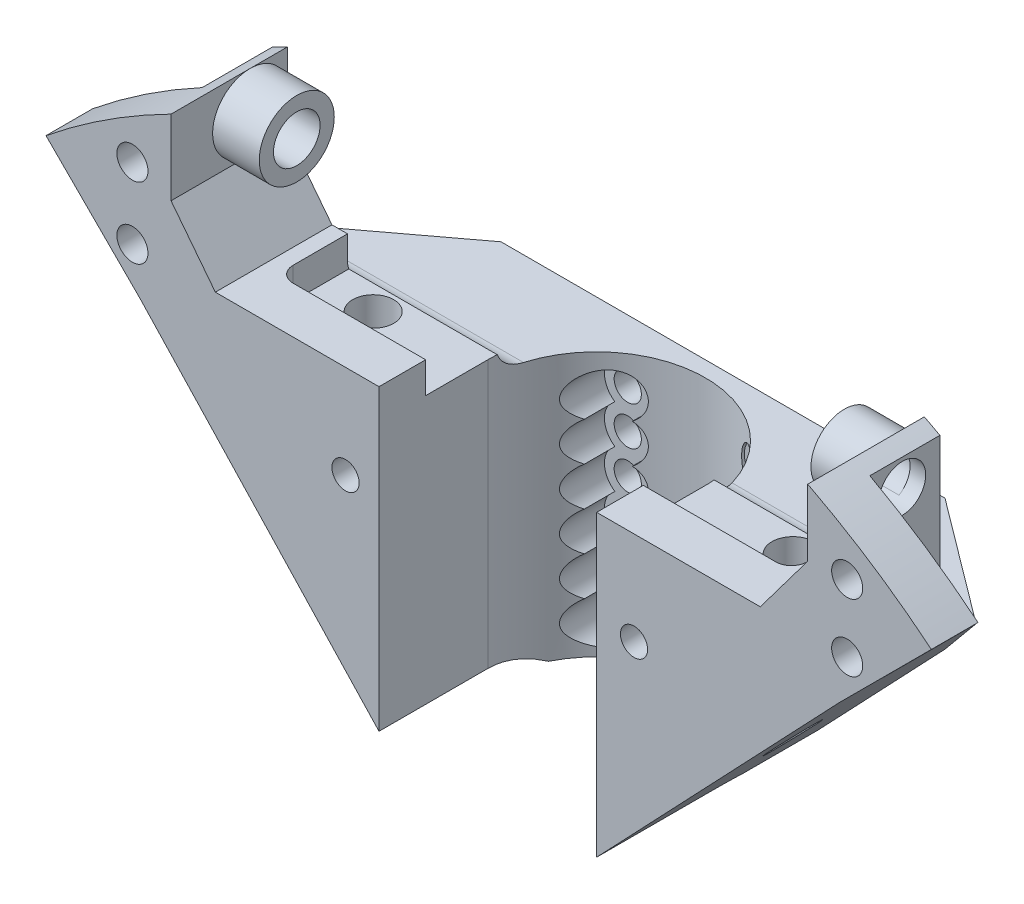
from build123d import *

# Parameters (mm, degrees)
BOSS_EXTRUDE1_DEPTH     = 30
CUT_EXTRUDE1_DEPTH      = 41
SKETCH4_R               = 1.999996
CUT_EXTRUDE2_DEPTH      = 31
CUT_EXTRUDE3_DEPTH      = 4
SKETCH6_W               = 121.245484342
SKETCH6_H               = 23
CUT_EXTRUDE4_DEPTH      = 15
SKETCH7_W               = 15.83545258
SKETCH7_H               = 23.773110715
SKETCH7_W_2             = 16.820183904
SKETCH7_H_2             = 28.417121519
CUT_EXTRUDE5_DEPTH      = 9
SKETCH8_R               = 4.826
SKETCH8_R_2             = 3
BOSS_EXTRUDE2_DEPTH     = 6
SKETCH10_R              = 4.29207203
SKETCH10_R_2            = 3
BOSS_EXTRUDE3_DEPTH     = 6
SKETCH9_R               = 3
CUT_EXTRUDE6_DEPTH      = 98.80678346
CUT_EXTRUDE6_DEPTH_BACK = 17.084465603
CUT_EXTRUDE7_START      = -9
CUT_EXTRUDE7_DEPTH      = 2
CUT_EXTRUDE8_DEPTH      = 34.985996
SKETCH13_R              = 3
CUT_EXTRUDE9_DEPTH      = 25
SKETCH14_R              = 1.75
CUT_EXTRUDE10_DEPTH     = 6
SKETCH16_R              = 3
CUT_EXTRUDE11_DEPTH     = 28
SKETCH17_R              = 1.75
CUT_EXTRUDE12_DEPTH     = 4
LPATTERN1_COUNT         = 6
LPATTERN1_PITCH         = 5
FILLET1_R               = 3
SKETCH18_R              = 2.643147836
SKETCH18_R_2            = 2.713759473
CUT_EXTRUDE13_DEPTH     = 37.0000001


with BuildPart() as part:
    # Sketch2 → Boss-Extrude1 (new body)
    with BuildSketch(Plane.XY):
        with BuildLine():
            Line((369.86928226, 192.180584327), (358.0270208, 180.34))
            Line((358.0270208, 180.34), (325.3150208, 145.928))
            Line((325.3150208, 145.928), (300.3150208, 145.928))
            Line((300.3150208, 145.928), (268.1110208, 180.34))
            Line((268.1110208, 180.34), (255.978033197, 192.47289829))
            ThreePointArc((255.978033197, 192.47289829), (263.741388347, 198.123056954), (272.0624988, 202.913996))
            Line((272.0624988, 202.913996), (272.0624988, 193.261996))
            Line((272.0624988, 193.261996), (277.7630208, 185.928))
            Line((277.7630208, 185.928), (347.8670208, 185.928))
            Line((347.8670208, 185.928), (353.9630208, 194.056))
            Line((353.9630208, 194.056), (353.9630208, 202.64014406))
            ThreePointArc((353.9630208, 202.64014406), (362.193484504, 197.832115291), (369.86928226, 192.180584327))
        make_face()
    extrude(amount=BOSS_EXTRUDE1_DEPTH)

    # Sketch3 → Cut-Extrude1 (cut, through all)
    with BuildSketch(Plane(origin=(0, 185.928, 0), x_dir=(1, 0, 0), z_dir=(0, 1, 0))):
        with BuildLine():
            Line((326.8150208, -16), (326.8150208, -30))
            Line((326.8150208, -30), (298.8150208, -30))
            Line((298.8150208, -30), (298.8150208, -16))
            ThreePointArc((298.8150208, -16), (312.8150208, -2), (326.8150208, -16))
        make_face()
    extrude(amount=-CUT_EXTRUDE1_DEPTH, mode=Mode.SUBTRACT)

    # Sketch4 → Cut-Extrude2 (cut, through all)
    with BuildSketch(Plane(origin=(0, 0, 0), x_dir=(-1, 0, 0), z_dir=(0, 0, -1))):
        with Locations((-359.0430208, 194.564)):
            Circle(SKETCH4_R)
        with Locations((-359.0430208, 185.928)):
            Circle(SKETCH4_R)
        with Locations((-267.0950208, 185.928)):
            Circle(SKETCH4_R)
        with Locations((-267.0950208, 195.072)):
            Circle(SKETCH4_R)
    extrude(amount=-CUT_EXTRUDE2_DEPTH, mode=Mode.SUBTRACT)

    # Sketch5 → Cut-Extrude3 (cut)
    with BuildSketch(Plane(origin=(0, 185.928, 0), x_dir=(1, 0, 0), z_dir=(0, 1, 0))):
        with BuildLine():
            Line((281.7630208, -10), (343.8670208, -10))
            ThreePointArc((343.8670208, -10), (345.281234362, -10.585786438), (345.8670208, -12))
            Line((345.8670208, -12), (345.8670208, -22))
            ThreePointArc((345.8670208, -22), (345.281234362, -23.414213562), (343.8670208, -24))
            Line((343.8670208, -24), (281.7630208, -24))
            ThreePointArc((281.7630208, -24), (280.348807238, -23.414213562), (279.7630208, -22))
            Line((279.7630208, -22), (279.7630208, -12))
            ThreePointArc((279.7630208, -12), (280.348807238, -10.585786438), (281.7630208, -10))
        make_face()
    extrude(amount=-CUT_EXTRUDE3_DEPTH, mode=Mode.SUBTRACT)

    # Sketch6 → Cut-Extrude4 (cut)
    with BuildSketch(Plane(origin=(0, 0, 0), x_dir=(-1, 0, 0), z_dir=(0, 0, -1))):
        with Locations((-313.202069465, 191.413996)):
            Rectangle(SKETCH6_W, SKETCH6_H)
    extrude(amount=-CUT_EXTRUDE4_DEPTH, mode=Mode.SUBTRACT)

    # Sketch7 → Cut-Extrude5 (cut)
    with BuildSketch(Plane(origin=(0, 0, 15), x_dir=(-1, 0, 0), z_dir=(0, 0, -1))):
        with Locations((-262.14477251, 191.800551358)):
            Rectangle(SKETCH7_W, SKETCH7_H)
        with Locations((-364.373112752, 194.12255676)):
            Rectangle(SKETCH7_W_2, SKETCH7_H_2)
    extrude(amount=-CUT_EXTRUDE5_DEPTH, mode=Mode.SUBTRACT)

    # Sketch8 → Boss-Extrude2 (add)
    with BuildSketch(Plane(origin=(272.0624988, 0, 0), x_dir=(0, 0, -1), z_dir=(1, 0, 0))):
        with Locations((-19.826, 198.087996)):
            Circle(SKETCH8_R)
        with Locations((-19.826, 198.087996)):
            Circle(SKETCH8_R_2, mode=Mode.SUBTRACT)
    extrude(amount=BOSS_EXTRUDE2_DEPTH)

    # Sketch10 → Boss-Extrude3 (add)
    with BuildSketch(Plane.ZY.offset(-353.9630208)):
        with Locations((19.29207203, 198.34807203)):
            Circle(SKETCH10_R)
        with Locations((19.29207203, 198.34807203)):
            Circle(SKETCH10_R_2, mode=Mode.SUBTRACT)
    extrude(amount=BOSS_EXTRUDE3_DEPTH)

    # Sketch9 → Cut-Extrude6 (cut, two sides)
    with BuildSketch(Plane(origin=(272.0624988, 0, 0), x_dir=(0, 0, -1), z_dir=(1, 0, 0))) as cut_extrude6_sk:
        with Locations((-19.826, 198.087996)):
            Circle(SKETCH9_R)
    extrude(amount=CUT_EXTRUDE6_DEPTH, mode=Mode.SUBTRACT)
    extrude(cut_extrude6_sk.sketch, amount=-CUT_EXTRUDE6_DEPTH_BACK, mode=Mode.SUBTRACT)

    # Sketch11 → Cut-Extrude7 (cut)
    with BuildSketch(Plane(origin=(0, 0, 15), x_dir=(-1, 0, 0), z_dir=(0, 0, -1)).offset(CUT_EXTRUDE7_START)):
        Polygon((-356.109034178, 187.142518768), (-358.627831595, 189.076166333), (-361.561818217, 187.861647565), (-361.977007422, 184.713481232), (-359.458210005, 182.779833667), (-356.524223383, 183.994352435), align=None)
        Polygon((-356.343621304, 192.891703467), (-356.245069772, 196.065600272), (-358.944469268, 197.737896805), (-361.742420296, 196.236296533), (-361.840971828, 193.062399728), (-359.141572332, 191.390103195), align=None)
        Polygon((-264.929327621, 188.250306265), (-268.023350431, 188.964698442), (-270.18904361, 186.642392178), (-269.260713979, 183.605693735), (-266.166691169, 182.891301558), (-264.00099799, 185.213607822), align=None)
        Polygon((-264.32278005, 193.523447592), (-264.367814701, 196.698554711), (-267.14005545, 198.247107118), (-269.86726155, 196.620552408), (-269.822226899, 193.445445289), (-267.04998615, 191.896892882), align=None)
    extrude(amount=-CUT_EXTRUDE7_DEPTH, mode=Mode.SUBTRACT)

    # Sketch12 → Cut-Extrude8 (cut, through all)
    with BuildSketch(Plane(origin=(0, 179.913996, 0), x_dir=(1, 0, 0), z_dir=(0, 1, 0))):
        Polygon((268.509690823, -12), (284.509690823, 0), (268.509690823, 0), align=None)
        Polygon((357.622061982, -12), (341.622061982, 0), (357.622061982, 0), align=None)
    extrude(amount=-CUT_EXTRUDE8_DEPTH, mode=Mode.SUBTRACT)

    # Sketch13 → Cut-Extrude9 (cut)
    with BuildSketch(Plane(origin=(0, 0, 0), x_dir=(-1, 0, 0), z_dir=(0, 0, -1))):
        with Locations((-331.622061982, 173.913996)):
            Circle(SKETCH13_R)
        with Locations((-294.509690823, 173.913996)):
            Circle(SKETCH13_R)
    extrude(amount=-CUT_EXTRUDE9_DEPTH, mode=Mode.SUBTRACT)

    # Sketch14 → Cut-Extrude10 (cut, through all)
    with BuildSketch(Plane(origin=(0, 0, 25), x_dir=(-1, 0, 0), z_dir=(0, 0, -1))):
        with Locations((-331.622061982, 173.913996)):
            Circle(SKETCH14_R)
        with Locations((-294.509690823, 173.913996)):
            Circle(SKETCH14_R)
    extrude(amount=-CUT_EXTRUDE10_DEPTH, mode=Mode.SUBTRACT)

    # Sketch16 → Cut-Extrude11 (cut, through all)
    with BuildSketch(Plane(origin=(0, 0, 3), x_dir=(-1, 0, 0), z_dir=(0, 0, -1))):
        with Locations((-321.8150208, 149.928)):
            Circle(SKETCH16_R)
        with Locations((-303.8150208, 149.928)):
            Circle(SKETCH16_R)
    cut_extrude11 = extrude(amount=-CUT_EXTRUDE11_DEPTH, mode=Mode.SUBTRACT)

    # Sketch17 → Cut-Extrude12 (cut, through all)
    with BuildSketch(Plane.XY.offset(3)):
        with Locations((303.8150208, 149.928)):
            Circle(SKETCH17_R)
        with Locations((321.8150208, 149.928)):
            Circle(SKETCH17_R)
    cut_extrude12 = extrude(amount=-CUT_EXTRUDE12_DEPTH, mode=Mode.SUBTRACT)

    # LPattern1: Cut-Extrude11, Cut-Extrude12 ×6
    with Locations(*[(0, i * LPATTERN1_PITCH, 0) for i in range(1, LPATTERN1_COUNT)]):
        add(cut_extrude11, mode=Mode.SUBTRACT)
        add(cut_extrude12, mode=Mode.SUBTRACT)

    # Fillet1
    fillet1_edges = [part.edges().sort_by_distance(p)[0] for p in [
        (341.371140822, 179.913996, 15),
        (284.456639778, 179.913996, 15),
    ]]
    fillet(fillet1_edges, radius=FILLET1_R)

    # Sketch18 → Cut-Extrude13 (cut, through all)
    with BuildSketch(Plane(origin=(0, 181.928, 0), x_dir=(1, 0, 0), z_dir=(0, 1, 0))):
        with Locations((286.065876402, -18)):
            Circle(SKETCH18_R)
        with Locations((340.065876402, -18)):
            Circle(SKETCH18_R_2)
    extrude(amount=-CUT_EXTRUDE13_DEPTH, mode=Mode.SUBTRACT)


solid = part.part
